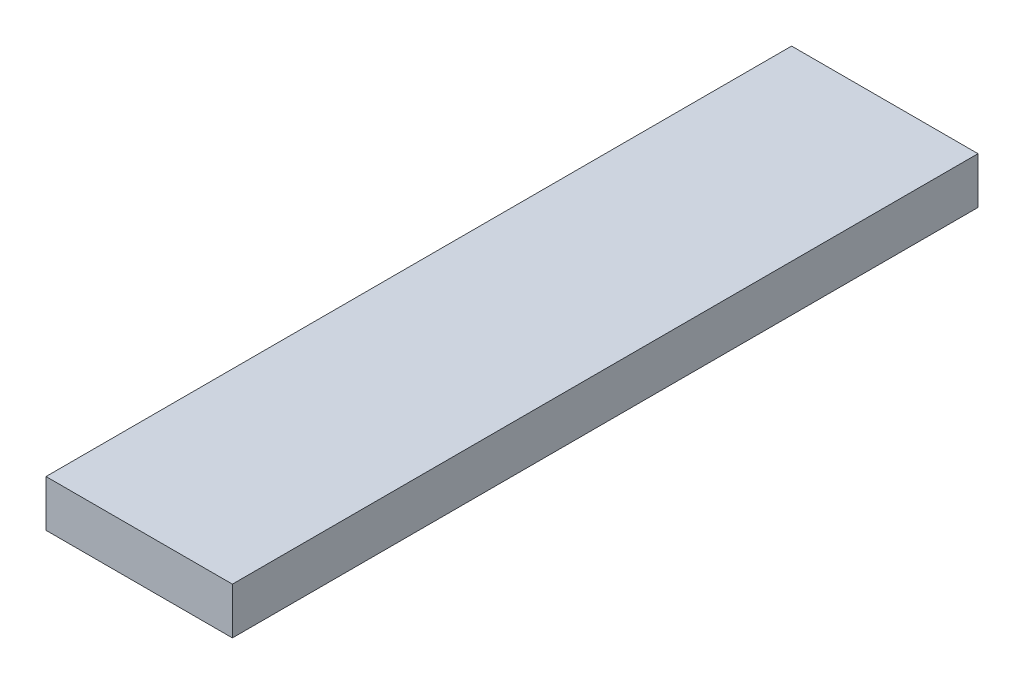
from build123d import *

# Parameters (mm, degrees)
SKETCH1_W           = 500
SKETCH1_H           = 2000
BOSS_EXTRUDE1_DEPTH = 125


with BuildPart() as part:
    # Sketch1 → Boss-Extrude1 (new body)
    with BuildSketch(Plane(origin=(0, 0, 0), x_dir=(1, 0, 0), z_dir=(0, 1, 0))):
        with Locations((291.13345521, -78.610603291)):
            Rectangle(SKETCH1_W, SKETCH1_H)
    extrude(amount=BOSS_EXTRUDE1_DEPTH)


solid = part.part
